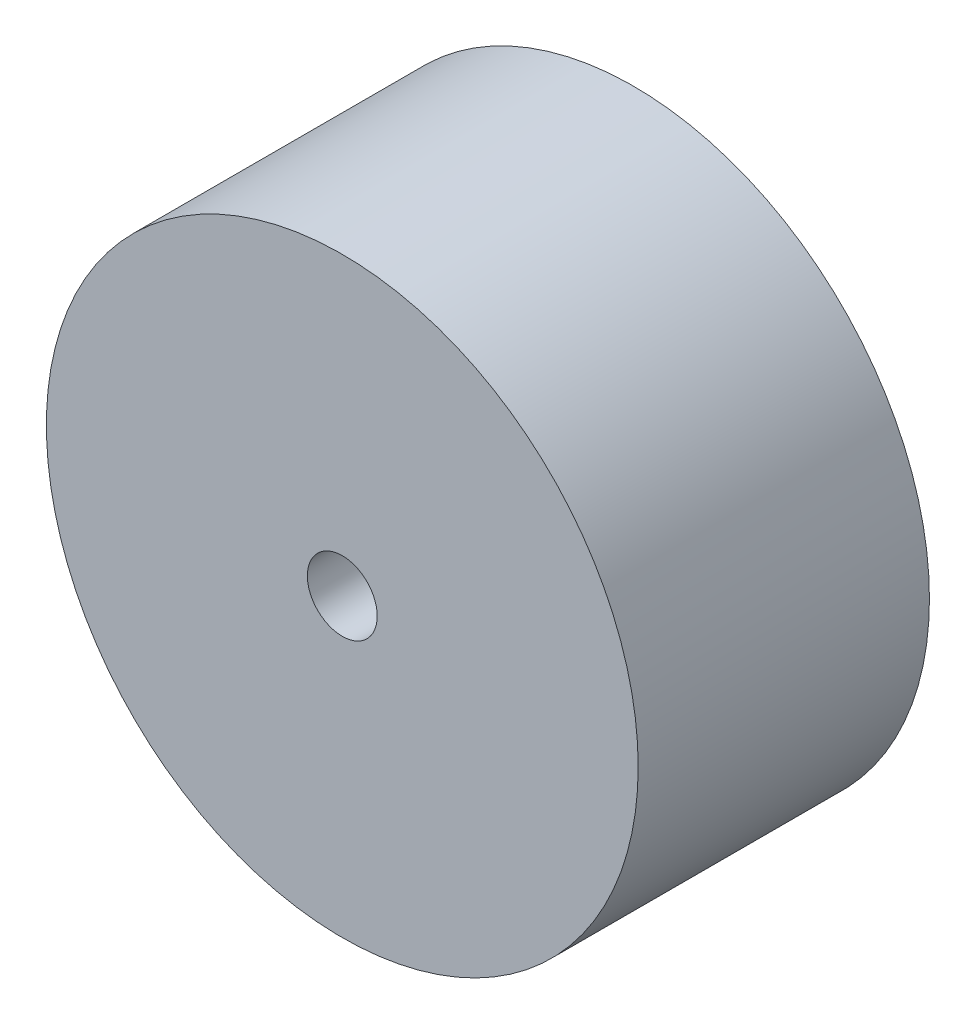
from build123d import *

# Parameters (mm, degrees)
SKETCH1_R           = 50.8
SKETCH1_R_2         = 6
BOSS_EXTRUDE1_DEPTH = 25


with BuildPart() as part:
    # Sketch1 → Boss-Extrude1 (new body, symmetric)
    with BuildSketch(Plane.XY):
        Circle(SKETCH1_R)
        Circle(SKETCH1_R_2, mode=Mode.SUBTRACT)
    extrude(amount=BOSS_EXTRUDE1_DEPTH, both=True)


solid = part.part
